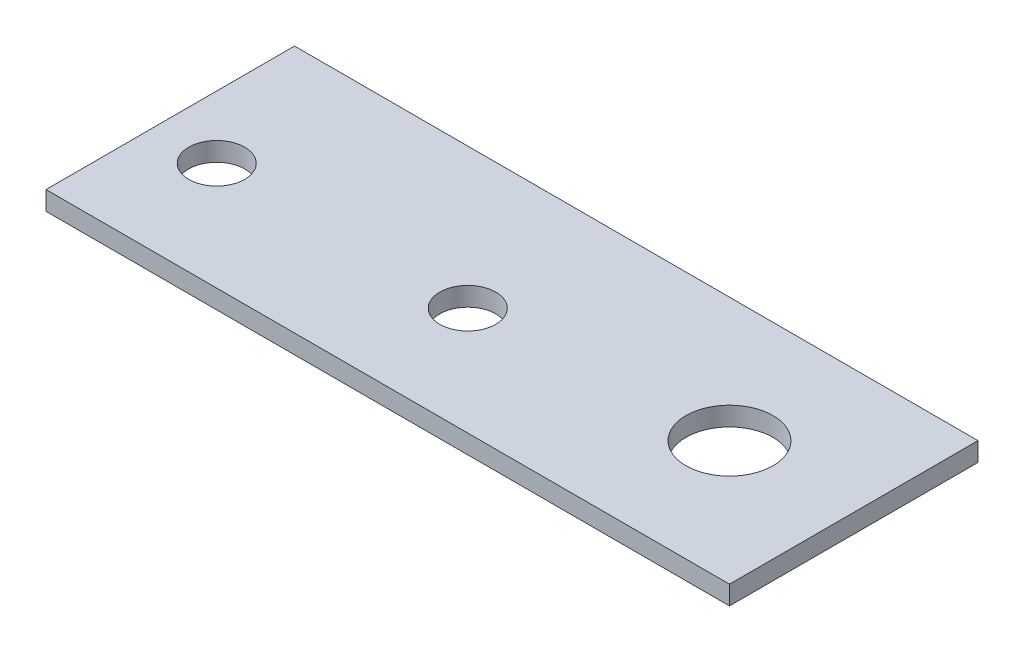
from build123d import *

# Parameters (mm, degrees)
SKETCH1_W           = 27.5
SKETCH1_H           = 10
SKETCH1_R           = 1.75
SKETCH1_R_2         = 1.125
BOSS_EXTRUDE1_DEPTH = 0.38


with BuildPart() as part:
    # Sketch1 → Boss-Extrude1 (new body, symmetric)
    with BuildSketch(Plane(origin=(0, 0, 0), x_dir=(1, 0, 0), z_dir=(0, 1, 0))):
        Rectangle(SKETCH1_W, SKETCH1_H)
        with Locations(Location((8.75, 0, 0), (0, 0, 270))):  # turned: the seam where the file's is
            Circle(SKETCH1_R, mode=Mode.SUBTRACT)
        with Locations(Location((-1.13, -0.65, 0), (0, 0, 270))):  # turned: the seam where the file's is
            Circle(SKETCH1_R_2, mode=Mode.SUBTRACT)
        with Locations(Location((-11.23, -0.65, 0), (0, 0, 270))):  # turned: the seam where the file's is
            Circle(SKETCH1_R_2, mode=Mode.SUBTRACT)
    extrude(amount=BOSS_EXTRUDE1_DEPTH, both=True)


solid = part.part
